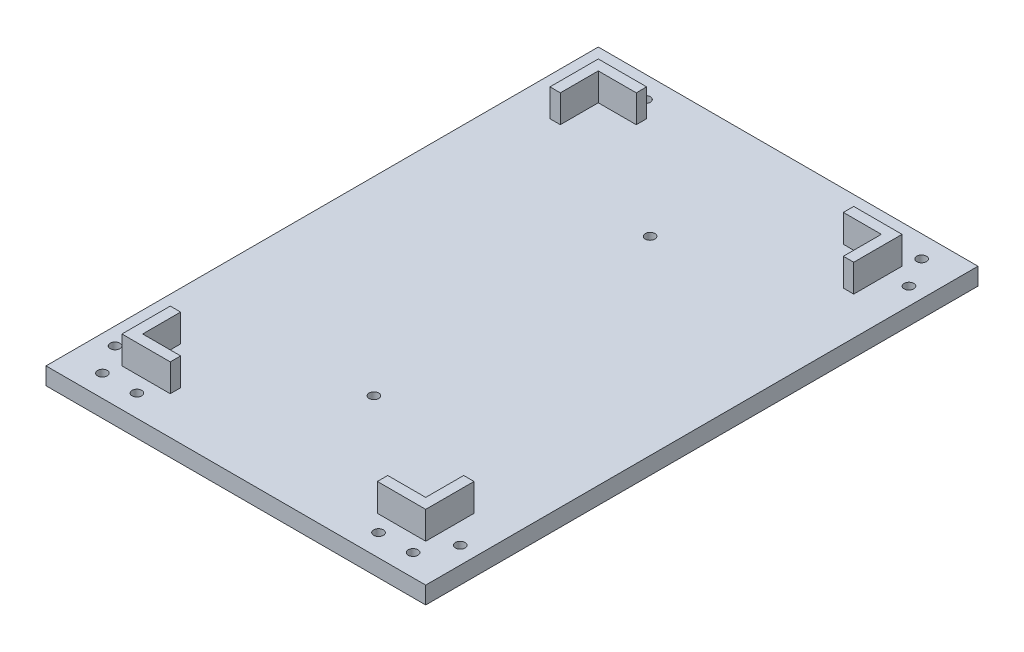
from build123d import *

# Parameters (mm, degrees)
SKETCH_1_W          = 110
SKETCH_1_H          = 160
EXTRUDE_1_DEPTH     = 5
SKETCH_3_R          = 1.4
CUT_EXTRUDE_1_DEPTH = 5
EXTRUDE_2_DEPTH     = 8
SKETCH_5_R          = 3
CUT_EXTRUDE_2_DEPTH = 2.5


with BuildPart() as part:
    # 스케치1 → 보스-돌출1 (new body)
    with BuildSketch(Plane(origin=(0, 0, 0), x_dir=(1, 0, 0), z_dir=(0, 1, 0))):
        Rectangle(SKETCH_1_W, SKETCH_1_H)
    extrude(amount=EXTRUDE_1_DEPTH)

    # 스케치3 → 컷-돌출1 (cut)
    with BuildSketch(Plane(origin=(0, 5, 0), x_dir=(1, 0, 0), z_dir=(0, 1, 0))):
        with Locations((-50, 65)):
            Circle(SKETCH_3_R)
        with Locations((-45, 73.660254038)):
            Circle(SKETCH_3_R)
        with Locations((-35, 73.660254038)):
            Circle(SKETCH_3_R)
        with Locations((-50, -65)):
            Circle(SKETCH_3_R)
        with Locations((-45, -73.660254038)):
            Circle(SKETCH_3_R)
        with Locations((-35, -73.660254038)):
            Circle(SKETCH_3_R)
        with Locations((35, 73.660254038)):
            Circle(SKETCH_3_R)
        with Locations((45, 73.660254038)):
            Circle(SKETCH_3_R)
        with Locations((50, 65)):
            Circle(SKETCH_3_R)
        with Locations((35, -73.660254038)):
            Circle(SKETCH_3_R)
        with Locations((45, -73.660254038)):
            Circle(SKETCH_3_R)
        with Locations((50, -65)):
            Circle(SKETCH_3_R)
        with Locations((0, 40)):
            Circle(SKETCH_3_R)
        with Locations((0, -40)):
            Circle(SKETCH_3_R)
    extrude(amount=-CUT_EXTRUDE_1_DEPTH, mode=Mode.SUBTRACT)

    # 스케치4 → 보스-돌출2 (add)
    with BuildSketch(Plane(origin=(0, 5, 0), x_dir=(1, 0, 0), z_dir=(0, 1, 0))):
        Polygon((41, 66), (30, 66), (30, 69), (44, 69), (44, 55), (41, 55), align=None)
        Polygon((44, -55), (41, -55), (41, -66), (30, -66), (30, -69), (44, -69), align=None)
        Polygon((-44, 55), (-41, 55), (-41, 66), (-30, 66), (-30, 69), (-44, 69), align=None)
        Polygon((-44, -55), (-41, -55), (-41, -66), (-30, -66), (-30, -69), (-44, -69), align=None)
    extrude(amount=EXTRUDE_2_DEPTH)

    # 스케치5 → 컷-돌출2 (cut)
    with BuildSketch(Plane.XZ):
        with Locations((0, 40)):
            Circle(SKETCH_5_R)
        with Locations((0, -40)):
            Circle(SKETCH_5_R)
    extrude(amount=-CUT_EXTRUDE_2_DEPTH, mode=Mode.SUBTRACT)


solid = part.part
